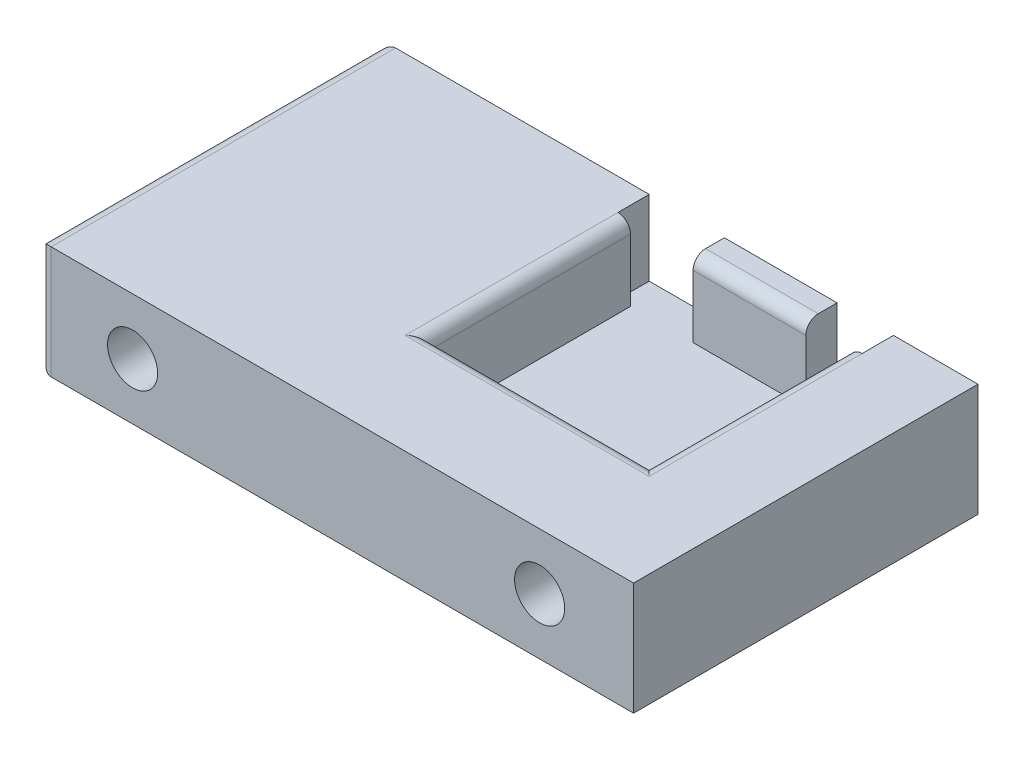
from build123d import *

# Parameters (mm, degrees)
SKETCH1_W           = 95
SKETCH1_H           = 55
BOSS_EXTRUDE1_DEPTH = 18
SKETCH2_R           = 4
CUT_EXTRUDE1_DEPTH  = 15
SKETCH3_W           = 35
SKETCH3_H           = 32
CUT_EXTRUDE2_DEPTH  = 12
FILLET2_R           = 2
SKETCH4_W           = 12
SKETCH4_H           = 5
CUT_EXTRUDE3_DEPTH  = 12
SKETCH5_W           = 9
SKETCH5_H           = 5
CUT_EXTRUDE4_DEPTH  = 12


with BuildPart() as part:
    # Sketch1 → Boss-Extrude1 (new body)
    with BuildSketch(Plane(origin=(0, 0, 0), x_dir=(1, 0, 0), z_dir=(0, 1, 0))):
        with Locations((47.5, -27.5)):
            Rectangle(SKETCH1_W, SKETCH1_H)
    extrude(amount=BOSS_EXTRUDE1_DEPTH)

    # Sketch2 → Cut-Extrude1 (cut)
    with BuildSketch(Plane.XY.offset(55)):
        with Locations((80, 9)):
            Circle(SKETCH2_R)
        with Locations((15, 9)):
            Circle(SKETCH2_R)
    extrude(amount=-CUT_EXTRUDE1_DEPTH, mode=Mode.SUBTRACT)

    # Sketch3 → Cut-Extrude2 (cut)
    with BuildSketch(Plane(origin=(0, 18, 0), x_dir=(1, 0, 0), z_dir=(0, 1, 0))):
        with Locations((62, -21)):
            Rectangle(SKETCH3_W, SKETCH3_H)
    extrude(amount=-CUT_EXTRUDE2_DEPTH, mode=Mode.SUBTRACT)

    # Fillet2
    fillet2_edges = [part.edges().sort_by_distance(p)[0] for p in [
        (44.5, 18, 21),
        (62, 18, 37),
        (79.5, 18, 21),
        (62, 18, 5),
        (0, 18, 27.5),
        (0, 0, 27.5),
        (0, 9, 0),
        (0, 9, 55),
    ]]
    fillet(fillet2_edges, radius=FILLET2_R)

    # Sketch4 → Cut-Extrude3 (cut)
    with BuildSketch(Plane(origin=(0, 18, 0), x_dir=(1, 0, 0), z_dir=(0, 1, 0))):
        with Locations((48.5, -2.5)):
            Rectangle(SKETCH4_W, SKETCH4_H)
    extrude(amount=-CUT_EXTRUDE3_DEPTH, mode=Mode.SUBTRACT)

    # Sketch5 → Cut-Extrude4 (cut)
    with BuildSketch(Plane(origin=(0, 18, 0), x_dir=(1, 0, 0), z_dir=(0, 1, 0))):
        with Locations((77, -2.5)):
            Rectangle(SKETCH5_W, SKETCH5_H)
    extrude(amount=-CUT_EXTRUDE4_DEPTH, mode=Mode.SUBTRACT)


solid = part.part
